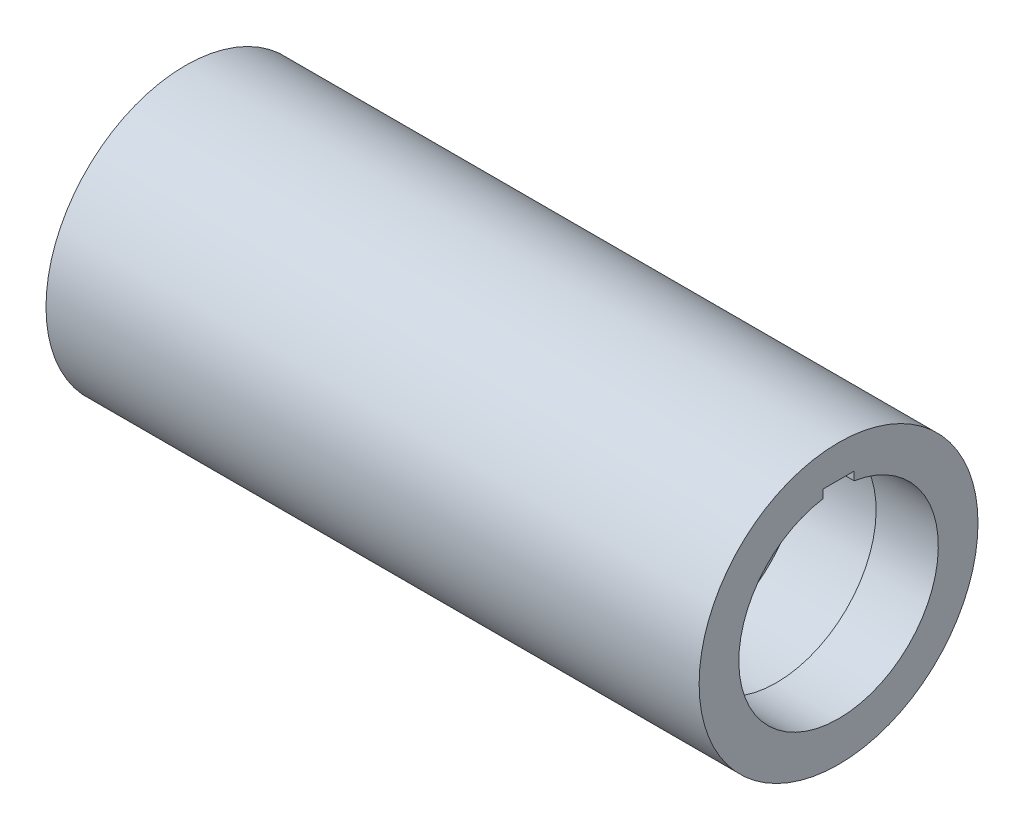
from build123d import *

# Parameters (mm, degrees)
SKETCH3_W          = 3
SKETCH3_H          = 1.6
CUT_EXTRUDE1_DEPTH = 64


with BuildPart() as part:
    # Sketch1 → Revolve1 (revolve)
    with BuildSketch(Plane.XY):
        Polygon((-31.5, 13.45), (31.5, 13.45), (31.5, 9.62162085), (25.5, 9.62162085), (25.5, 10.42162085), (17.5, 10.42162085), (17.5, 9.62162085), (-31.5, 9.62162085), align=None)
    revolve(axis=Axis((-66.372744643, 0, 0), (1, 0, 0)))

    # Sketch3 → Cut-Extrude1 (cut, through all)
    with BuildSketch(Plane(origin=(31.5, 0, 0), x_dir=(0, 0, -1), z_dir=(1, 0, 0))):
        with Locations((0, 9.511869156)):
            Rectangle(SKETCH3_W, SKETCH3_H)
    extrude(amount=-CUT_EXTRUDE1_DEPTH, mode=Mode.SUBTRACT)


solid = part.part
